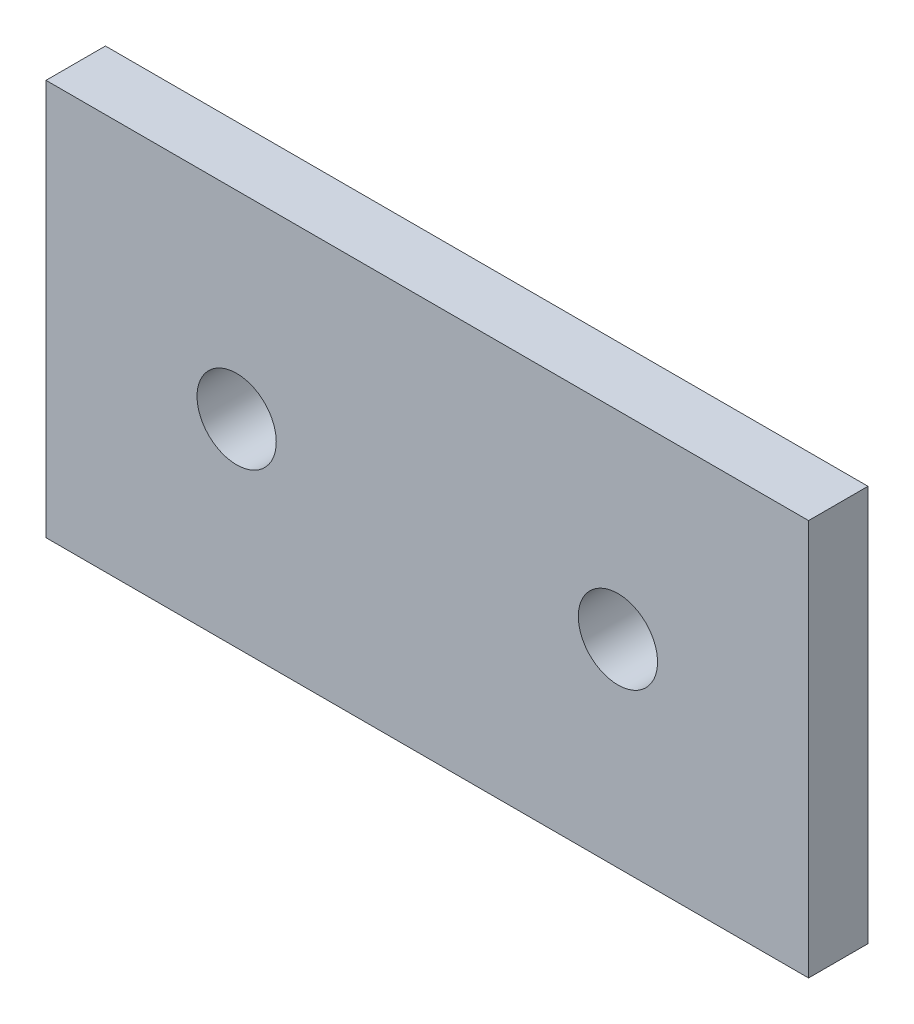
from build123d import *

# Parameters (mm, degrees)
CROQUIS1_W              = 38.5
CROQUIS1_H              = 20
SALIENTE_EXTRUIR1_DEPTH = 3
CROQUIS3_R              = 2
CORTAR_EXTRUIR1_DEPTH   = 3


with BuildPart() as part:
    # Croquis1 → Saliente-Extruir1 (new body)
    with BuildSketch(Plane.XY):
        with Locations((-19.25, 10)):
            Rectangle(CROQUIS1_W, CROQUIS1_H)
    extrude(amount=SALIENTE_EXTRUIR1_DEPTH)

    # Croquis3 → Cortar-Extruir1 (cut)
    with BuildSketch(Plane(origin=(0, 0, 0), x_dir=(-1, 0, 0), z_dir=(0, 0, -1))):
        with Locations((9.625, 10)):
            Circle(CROQUIS3_R)
        with Locations((28.875, 10)):
            Circle(CROQUIS3_R)
    extrude(amount=-CORTAR_EXTRUIR1_DEPTH, mode=Mode.SUBTRACT)


solid = part.part
